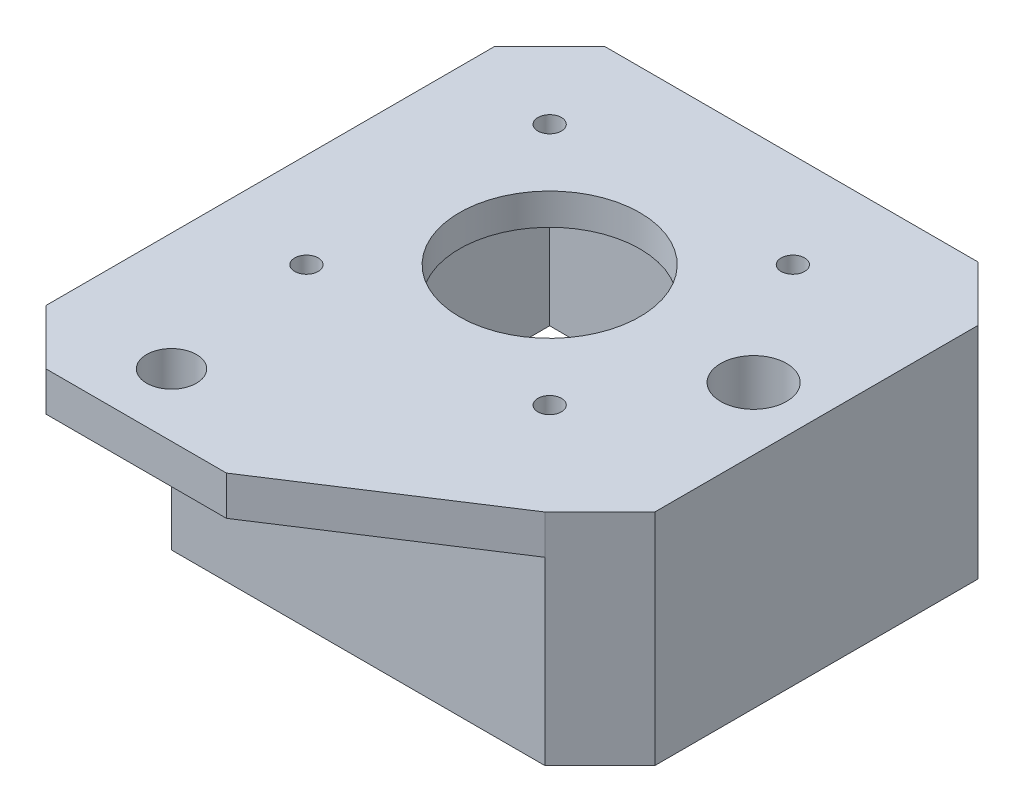
from build123d import *

# Parameters (mm, degrees)
SKETCH1_W            = 55
SKETCH1_H            = 42
SKETCH1_R            = 4.2
SKETCH1_R_2          = 11.5
SKETCH1_R_3          = 1.5
BOSS_EXTRUDE1_DEPTH  = 4
SKETCH2_R            = 4.2
BOSS_EXTRUDE2_DEPTH  = 20
SKETCH3_W            = 12.75
SKETCH3_H            = 20
BOSS_EXTRUDE3_DEPTH  = 4
SKETCH4_W            = 55.2
SKETCH4_H            = 55.2
SKETCH4_W_2          = 42.5
SKETCH4_H_2          = 42.5
BOSS_EXTRUDE4_DEPTH  = 24
SKETCH5_R            = 4.2
CUT_EXTRUDE1_DEPTH   = 20
SKETCH6_W            = 6.6
SKETCH6_H            = 4
BOSS_EXTRUDE6_DEPTH  = 48.6
SKETCH7_W            = 6.6
SKETCH7_H            = 4
BOSS_EXTRUDE7_DEPTH  = 55.2
BOSS_EXTRUDE8_DEPTH  = 6.4
CUT_EXTRUDE2_DEPTH   = 28
SKETCH10_R           = 3.175
BOSS_EXTRUDE10_DEPTH = 5


with BuildPart() as part:
    # Sketch1 → Boss-Extrude1 (new body)
    with BuildSketch(Plane(origin=(0, 0, 0), x_dir=(1, 0, 0), z_dir=(0, 1, 0))):
        with Locations((27.5, 21)):
            Rectangle(SKETCH1_W, SKETCH1_H)
        with Locations((47, 21)):
            Circle(SKETCH1_R, mode=Mode.SUBTRACT)
        with Locations((21, 21)):
            Circle(SKETCH1_R_2, mode=Mode.SUBTRACT)
        with Locations((5.5, 36.5)):
            Circle(SKETCH1_R_3, mode=Mode.SUBTRACT)
        with Locations((36.5, 36.5)):
            Circle(SKETCH1_R_3, mode=Mode.SUBTRACT)
        with Locations((5.5, 5.5)):
            Circle(SKETCH1_R_3, mode=Mode.SUBTRACT)
        with Locations((36.5, 5.5)):
            Circle(SKETCH1_R_3, mode=Mode.SUBTRACT)
    extrude(amount=BOSS_EXTRUDE1_DEPTH)

    # Sketch2 → Boss-Extrude2 (add)
    with BuildSketch(Plane.XZ):
        with BuildLine():
            ThreePointArc((53.6, -21), (49.47082982, -14.879950981), (42.25, -16.417697086))
            Line((42.25, -16.417697086), (42.25, -25.582302914))
            ThreePointArc((42.25, -25.582302914), (49.47082982, -27.120049019), (53.6, -21))
        make_face()
        with Locations((47, -21)):
            Circle(SKETCH2_R, mode=Mode.SUBTRACT)
        with BuildLine():
            Line((55, -11), (42.25, -11))
            Line((42.25, -11), (42.25, -16.417697086))
            ThreePointArc((42.25, -16.417697086), (49.47082982, -14.879950981), (53.6, -21))
            ThreePointArc((53.6, -21), (49.47082982, -27.120049019), (42.25, -25.582302914))
            Line((42.25, -25.582302914), (42.25, -31))
            Line((42.25, -31), (55, -31))
            Line((55, -31), (55, -11))
        make_face()
    extrude(amount=BOSS_EXTRUDE2_DEPTH)

    # Sketch3 → Boss-Extrude3 (add)
    with BuildSketch(Plane.XZ.offset(20)):
        with Locations((48.625, -21)):
            Rectangle(SKETCH3_W, SKETCH3_H)
    extrude(amount=BOSS_EXTRUDE3_DEPTH)

    # Sketch4 → Boss-Extrude4 (add)
    with BuildSketch(Plane.XZ):
        with Locations((21, -21)):
            Rectangle(SKETCH4_W, SKETCH4_H)
        with Locations((21, -21)):
            Rectangle(SKETCH4_W_2, SKETCH4_H_2, mode=Mode.SUBTRACT)
    extrude(amount=BOSS_EXTRUDE4_DEPTH)

    # Sketch5 → Cut-Extrude1 (cut)
    with BuildSketch(Plane(origin=(0, 0, 0), x_dir=(1, 0, 0), z_dir=(0, 1, 0))):
        with Locations((47, 21)):
            Circle(SKETCH5_R)
    extrude(amount=-CUT_EXTRUDE1_DEPTH, mode=Mode.SUBTRACT)

    # Sketch6 → Boss-Extrude6 (add)
    with BuildSketch(Plane(origin=(48.6, 0, 0), x_dir=(0, 0, -1), z_dir=(1, 0, 0))):
        with Locations((45.3, 2)):
            Rectangle(SKETCH6_W, SKETCH6_H)
        with Locations((-3.3, 2)):
            Rectangle(SKETCH6_W, SKETCH6_H)
    extrude(amount=-BOSS_EXTRUDE6_DEPTH)

    # Sketch7 → Boss-Extrude7 (add)
    with BuildSketch(Plane(origin=(0, 0, -48.6), x_dir=(-1, 0, 0), z_dir=(0, 0, -1))):
        with Locations((3.3, 2)):
            Rectangle(SKETCH7_W, SKETCH7_H)
    extrude(amount=-BOSS_EXTRUDE7_DEPTH)

    # Sketch8 → Boss-Extrude8 (add)
    with BuildSketch(Plane(origin=(48.6, 0, 0), x_dir=(0, 0, -1), z_dir=(1, 0, 0))):
        Polygon((42, 0), (31, 0), (31, -24), (48.6, -24), (48.6, 4), (42, 4), align=None)
        Polygon((11, -24), (11, 0), (0, 0), (0, 4), (-6.6, 4), (-6.6, -24), align=None)
    extrude(amount=BOSS_EXTRUDE8_DEPTH)

    # Sketch9 → Cut-Extrude2 (cut)
    with BuildSketch(Plane(origin=(0, 4, 0), x_dir=(1, 0, 0), z_dir=(0, 1, 0))):
        Polygon((55, 0.4), (48, -6.6), (55, -6.6), align=None)
        Polygon((55, 41.6), (48, 48.6), (55, 48.6), align=None)
        Polygon((0.4, 48.6), (-6.6, 48.6), (-6.6, 41.6), align=None)
        Polygon((0.4, -6.6), (-6.6, 0.4), (-6.6, -6.6), align=None)
    extrude(amount=-CUT_EXTRUDE2_DEPTH, mode=Mode.SUBTRACT)

    # Sketch10 → Boss-Extrude10 (add)
    with BuildSketch(Plane(origin=(0, 4, 0), x_dir=(1, 0, 0), z_dir=(0, 1, 0))):
        Polygon((0.4, -6.6), (-6.6, 0.4), (-6.6, -15.6), (0.4, -22.6), (23.4, -22.6), (23.4, -6.6), align=None)
        with Locations((8.4, -14.6)):
            Circle(SKETCH10_R, mode=Mode.SUBTRACT)
        Polygon((48, -6.6), (23.4, -6.6), (23.4, -22.6), align=None)
    extrude(amount=-BOSS_EXTRUDE10_DEPTH)


solid = part.part
